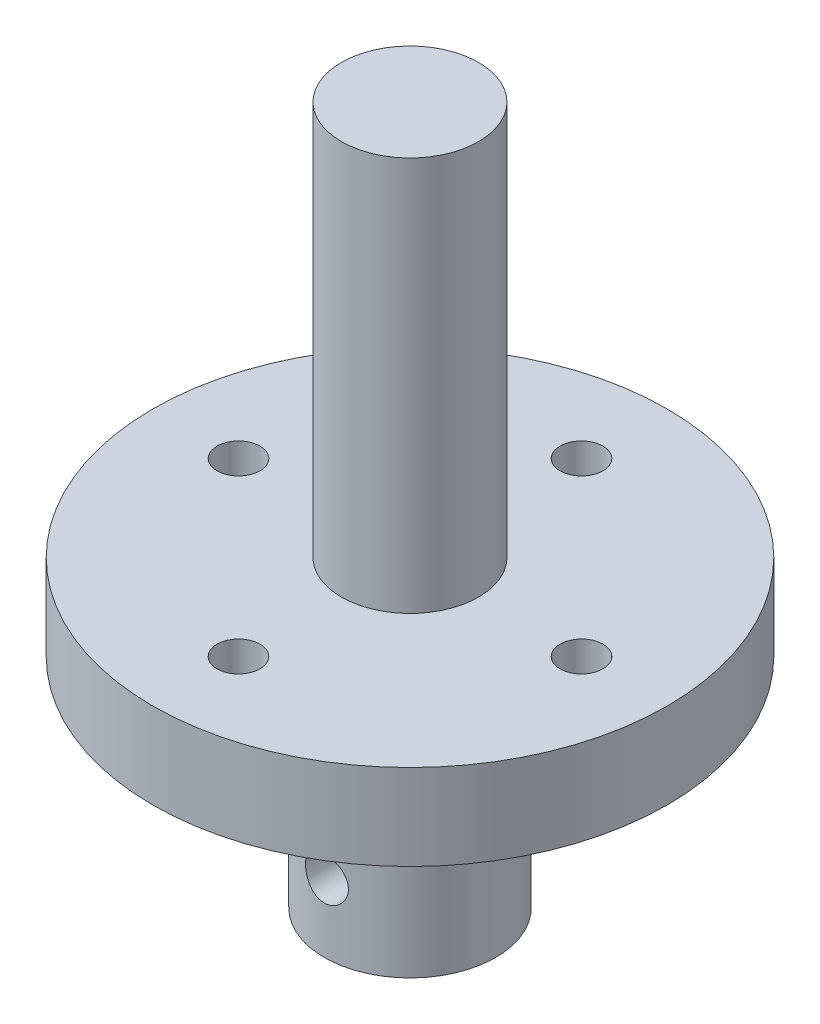
from build123d import *

# Parameters (mm, degrees)
SKETCH1_R                 = 15
BOSS_EXTRUDE1_DEPTH       = 5
SKETCH2_R                 = 5
BOSS_EXTRUDE2_DEPTH       = 12.7
SKETCH3_R                 = 2
CUT_EXTRUDE1_DEPTH        = 9.5
SKETCH5_R                 = 1.25
CUT_EXTRUDE2_DEPTH        = 5
CIRPATTERN1_COUNT         = 4
M3X0_5_TAPPED_HOLE1_D     = 2.5
M3X0_5_TAPPED_HOLE2_D     = 2.5
M3X0_5_TAPPED_HOLE2_DEPTH = 4.999
M3X0_5_TAPPED_HOLE2_TIP   = 0.751075774
SKETCH12_R                = 4
BOSS_EXTRUDE3_DEPTH       = 23


with BuildPart() as part:
    # Sketch1 → Boss-Extrude1 (new body)
    with BuildSketch(Plane(origin=(0, 0, 0), x_dir=(1, 0, 0), z_dir=(0, 1, 0))):
        Circle(SKETCH1_R)
    extrude(amount=BOSS_EXTRUDE1_DEPTH)

    # Sketch2 → Boss-Extrude2 (add)
    with BuildSketch(Plane.XZ):
        Circle(SKETCH2_R)
    extrude(amount=BOSS_EXTRUDE2_DEPTH)

    # Sketch3 → Cut-Extrude1 (cut)
    with BuildSketch(Plane.XZ.offset(12.7)):
        Circle(SKETCH3_R)
    extrude(amount=-CUT_EXTRUDE1_DEPTH, mode=Mode.SUBTRACT)

    # Sketch5 → Cut-Extrude2 (cut)
    with BuildSketch(Plane(origin=(0, 5, 0), x_dir=(1, 0, 0), z_dir=(0, 1, 0))):
        with Locations((0, -10)):
            Circle(SKETCH5_R)
    cut_extrude2 = extrude(amount=-CUT_EXTRUDE2_DEPTH, mode=Mode.SUBTRACT)

    # CirPattern1: Cut-Extrude2 ×4 about axis
    cirpattern1_axis = Axis((0, 0, 0), (0, 1, 0))
    for i in range(1, CIRPATTERN1_COUNT):
        add(cut_extrude2.rotate(cirpattern1_axis, i * 360 / CIRPATTERN1_COUNT), mode=Mode.SUBTRACT)

    # M3x0.5 Tapped Hole1 (through all)
    with Locations(Plane(origin=(0, 5, 0), x_dir=(1, 0, 0), z_dir=(0, 1, 0))):
        with Locations((-10, 0), (0, -10), (10, 0), (0, 10)):
            Hole(M3X0_5_TAPPED_HOLE1_D / 2)

    # M3x0.5 Tapped Hole2
    with Locations(Plane.XY.offset(5)):
        with Locations((0, -8.7)):
            Hole(M3X0_5_TAPPED_HOLE2_D / 2, depth=M3X0_5_TAPPED_HOLE2_DEPTH)
            with Locations((0, 0, -(M3X0_5_TAPPED_HOLE2_DEPTH + M3X0_5_TAPPED_HOLE2_TIP / 2))):  # 118° drill point
                Cone(0, M3X0_5_TAPPED_HOLE2_D / 2, M3X0_5_TAPPED_HOLE2_TIP, mode=Mode.SUBTRACT)

    # Sketch12 → Boss-Extrude3 (add)
    with BuildSketch(Plane(origin=(0, 5, 0), x_dir=(1, 0, 0), z_dir=(0, 1, 0))):
        Circle(SKETCH12_R)
    extrude(amount=BOSS_EXTRUDE3_DEPTH)


solid = part.part
